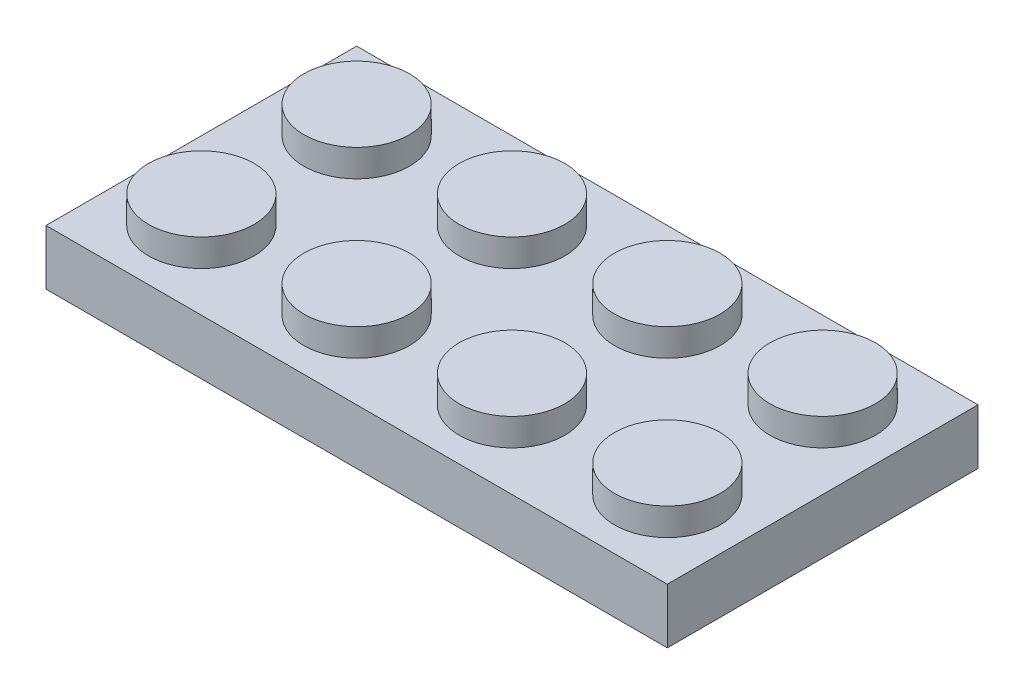
from build123d import *

# Parameters (mm, degrees)
SKETCH1_W            = 31.75
SKETCH1_H            = 15.875
BOSS_EXTRUDE1_DEPTH  = 1.4097
SKETCH2_W            = 29.21
SKETCH2_H            = 13.335
SKETCH2_R            = 3.175
SKETCH2_R_2          = 2.413
CUT_EXTRUDE1_DEPTH   = 1.5494
SKETCH3_R            = 2.69875
BOSS_EXTRUDE2_DEPTH  = 1.397
LPATTERN1_COUNT      = 4
LPATTERN1_PITCH      = 7.9375
LPATTERN1_COUNT_DIR2 = 2
LPATTERN1_PITCH_DIR2 = 7.9375
SKETCH2_3_R          = 3.175
SKETCH2_3_R_2        = 2.413
BOSS_EXTRUDE3_DEPTH  = 1.5494
LPATTERN2_COUNT      = 2
LPATTERN2_PITCH      = 7.9375
LPATTERN2_COL_COUNT  = 2
LPATTERN2_COL_PITCH  = 7.9375


with BuildPart() as part:
    # Sketch1 → Boss-Extrude1 (new, symmetric)
    with BuildSketch(Plane(origin=(0, 0, 0), x_dir=(1, 0, 0), z_dir=(0, 1, 0))):
        Rectangle(SKETCH1_W, SKETCH1_H)
    extrude(amount=BOSS_EXTRUDE1_DEPTH, both=True)

    # Sketch2 → Cut-Extrude1 (cut)
    with BuildSketch(Plane.XZ.offset(1.4097)):
        Rectangle(SKETCH2_W, SKETCH2_H)
        Circle(SKETCH2_R, mode=Mode.SUBTRACT)
        Circle(SKETCH2_R)
        Circle(SKETCH2_R_2, mode=Mode.SUBTRACT)
        Circle(SKETCH2_R_2)
    extrude(amount=-CUT_EXTRUDE1_DEPTH, mode=Mode.SUBTRACT)

    # Sketch3 → Boss-Extrude2 (add)
    with BuildSketch(Plane(origin=(0, 1.4097, 0), x_dir=(1, 0, 0), z_dir=(0, 1, 0))):
        with Locations(Location((11.90625, -3.96875, 0), (0, 0, 90))):
            Circle(SKETCH3_R)
    boss_extrude2 = extrude(amount=BOSS_EXTRUDE2_DEPTH)

    # LPattern1: Boss-Extrude2 4 × 2
    with Locations(*[(-i * LPATTERN1_PITCH, 0, -j * LPATTERN1_PITCH_DIR2) for i in range(LPATTERN1_COUNT) for j in range(LPATTERN1_COUNT_DIR2) if (i, j) != (0, 0)]):
        add(boss_extrude2)

    # Sketch2_3 → Boss-Extrude3 (add)
    with BuildSketch(Plane.XZ.offset(1.4097)):
        with Locations(Location((0, 0, 0), (0, 0, 270))):
            Circle(SKETCH2_3_R)
        with Locations(Location((0, 0, 0), (0, 0, 270))):
            Circle(SKETCH2_3_R_2, mode=Mode.SUBTRACT)
    boss_extrude3 = extrude(amount=-BOSS_EXTRUDE3_DEPTH)

    # LPattern2: Boss-Extrude3 ×2
    with Locations(*[(i * LPATTERN2_PITCH, 0, 0) for i in range(1, LPATTERN2_COUNT)]):
        add(boss_extrude3)

    # LPattern2 col: Boss-Extrude3 ×2
    with Locations(*[(-i * LPATTERN2_COL_PITCH, 0, 0) for i in range(1, LPATTERN2_COL_COUNT)]):
        add(boss_extrude3)


solid = part.part
